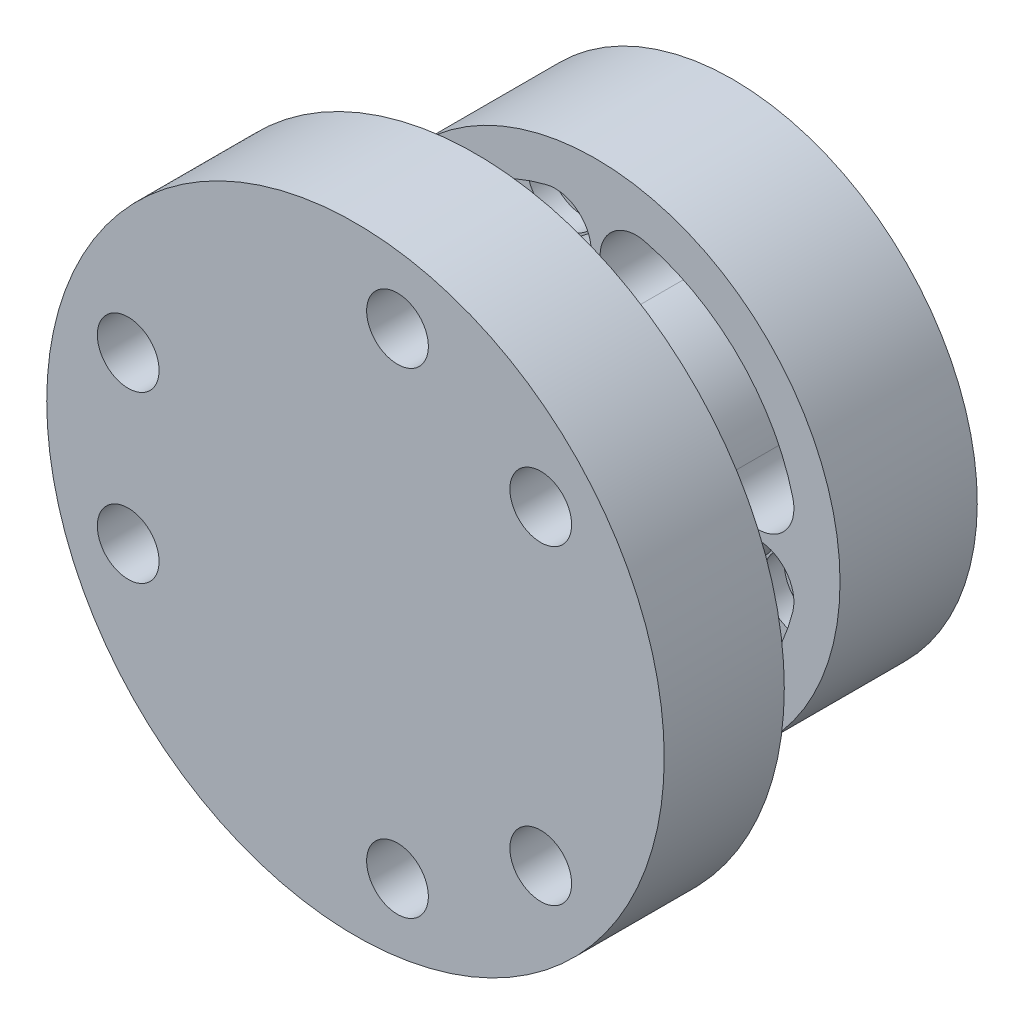
from build123d import *

# Parameters (mm, degrees)
SKETCH_1_R                   = 1.1
EXTRUDE_1_DEPTH              = 3
SKETCH_2_R                   = 2.1
CUT_EXTRUDE_1_DEPTH          = 1.2
SKETCH_3_R                   = 14.25
SKETCH_3_R_2                 = 11.85
EXTRUDE_2_DEPTH              = 1
SKETCH_4_R                   = 14.25
EXTRUDE_3_DEPTH              = 4
SKETCH_5_R                   = 3.25
CUT_EXTRUDE_2_DEPTH          = 2.5
SKETCH_6_R                   = 3.5
EXTRUDE_4_DEPTH              = 7
SKETCH_7_R                   = 18
SKETCH_7_R_2                 = 1.6
EXTRUDE_5_DEPTH              = 7
HOLE_WIZARD_M3_1_D           = 3.6
HOLE_WIZARD_M3_1_DEPTH       = 7
HOLE_WIZARD_M3_1_CSINK_D     = 6.3
HOLE_WIZARD_M3_1_CSINK_ANGLE = 90


with BuildPart() as part:
    # 스케치1 → 보스-돌출1 (new body)
    with BuildSketch(Plane.XY):
        with BuildLine():
            Line((-4.25, -5.562148865), (-4.25, -13.601470509))
            ThreePointArc((-4.25, -13.601470509), (0, 14.25), (4.25, -13.601470509))
            Line((4.25, -13.601470509), (4.25, -5.562148865))
            ThreePointArc((4.25, -5.562148865), (0, 7), (-4.25, -5.562148865))
        make_face()
        with Locations((6.894291117, 6.894291117)):
            Circle(SKETCH_1_R, mode=Mode.SUBTRACT)
        with Locations((6.894291117, -6.894291117)):
            Circle(SKETCH_1_R, mode=Mode.SUBTRACT)
        with Locations((-6.894291117, -6.894291117)):
            Circle(SKETCH_1_R, mode=Mode.SUBTRACT)
        with Locations((-6.894291117, 6.894291117)):
            Circle(SKETCH_1_R, mode=Mode.SUBTRACT)
    extrude(amount=EXTRUDE_1_DEPTH)

    # 스케치2 → 컷-돌출1 (cut)
    with BuildSketch(Plane.XY.offset(3)):
        with Locations((-6.894291117, 6.894291117)):
            Circle(SKETCH_2_R)
        with Locations((6.894291117, 6.894291117)):
            Circle(SKETCH_2_R)
        with Locations((6.894291117, -6.894291117)):
            Circle(SKETCH_2_R)
        with Locations((-6.894291117, -6.894291117)):
            Circle(SKETCH_2_R)
    extrude(amount=-CUT_EXTRUDE_1_DEPTH, mode=Mode.SUBTRACT)

    # 스케치3 → 보스-돌출2 (add)
    with BuildSketch(Plane.XY.offset(3)):
        Circle(SKETCH_3_R)
        Circle(SKETCH_3_R_2, mode=Mode.SUBTRACT)
    extrude(amount=EXTRUDE_2_DEPTH)

    # 스케치4 → 보스-돌출3 (add)
    with BuildSketch(Plane.XY.offset(4)):
        Circle(SKETCH_4_R)
        with BuildLine():
            ThreePointArc((11.498004356, 2.866774463), (8.379215357, 8.379215357), (2.866774463, 11.498004356))
            ThreePointArc((2.866774463, 11.498004356), (0.321117457, 9.968419312), (1.850702501, 7.422762306))
            ThreePointArc((1.850702501, 7.422762306), (5.409366876, 5.409366876), (7.422762306, 1.850702501))
            ThreePointArc((7.422762306, 1.850702501), (9.968419312, 0.321117457), (11.498004356, 2.866774463))
        make_face(mode=Mode.SUBTRACT)
        with BuildLine():
            ThreePointArc((2.866774463, -11.498004356), (8.379215357, -8.379215357), (11.498004356, -2.866774463))
            ThreePointArc((11.498004356, -2.866774463), (9.968419312, -0.321117457), (7.422762306, -1.850702501))
            ThreePointArc((7.422762306, -1.850702501), (5.409366876, -5.409366876), (1.850702501, -7.422762306))
            ThreePointArc((1.850702501, -7.422762306), (0.321117457, -9.968419312), (2.866774463, -11.498004356))
        make_face(mode=Mode.SUBTRACT)
        with BuildLine():
            ThreePointArc((-11.498004356, -2.866774463), (-8.379215357, -8.379215357), (-2.866774463, -11.498004356))
            ThreePointArc((-2.866774463, -11.498004356), (-0.321117457, -9.968419312), (-1.850702501, -7.422762306))
            ThreePointArc((-1.850702501, -7.422762306), (-5.409366876, -5.409366876), (-7.422762306, -1.850702501))
            ThreePointArc((-7.422762306, -1.850702501), (-9.968419312, -0.321117457), (-11.498004356, -2.866774463))
        make_face(mode=Mode.SUBTRACT)
        with BuildLine():
            ThreePointArc((-2.866774463, 11.498004356), (-8.379215357, 8.379215357), (-11.498004356, 2.866774463))
            ThreePointArc((-11.498004356, 2.866774463), (-9.968419312, 0.321117457), (-7.422762306, 1.850702501))
            ThreePointArc((-7.422762306, 1.850702501), (-5.409366876, 5.409366876), (-1.850702501, 7.422762306))
            ThreePointArc((-1.850702501, 7.422762306), (-0.321117457, 9.968419312), (-2.866774463, 11.498004356))
        make_face(mode=Mode.SUBTRACT)
        with BuildLine():
            ThreePointArc((3.40366883, 6.401370048), (0, 7.25), (-3.40366883, 6.401370048))
            ThreePointArc((-3.40366883, 6.401370048), (-4.023882875, 4.372741315), (-1.995254142, 3.75252727))
            ThreePointArc((-1.995254142, 3.75252727), (0, 4.25), (1.995254142, 3.75252727))
            ThreePointArc((1.995254142, 3.75252727), (4.023882875, 4.372741315), (3.40366883, 6.401370048))
        make_face(mode=Mode.SUBTRACT)
        with BuildLine():
            ThreePointArc((6.401370048, -3.40366883), (7.25, 0), (6.401370048, 3.40366883))
            ThreePointArc((6.401370048, 3.40366883), (4.372741315, 4.023882875), (3.75252727, 1.995254142))
            ThreePointArc((3.75252727, 1.995254142), (4.25, 0), (3.75252727, -1.995254142))
            ThreePointArc((3.75252727, -1.995254142), (4.372741315, -4.023882875), (6.401370048, -3.40366883))
        make_face(mode=Mode.SUBTRACT)
        with BuildLine():
            ThreePointArc((-3.40366883, -6.401370048), (0, -7.25), (3.40366883, -6.401370048))
            ThreePointArc((3.40366883, -6.401370048), (4.023882875, -4.372741315), (1.995254142, -3.75252727))
            ThreePointArc((1.995254142, -3.75252727), (0, -4.25), (-1.995254142, -3.75252727))
            ThreePointArc((-1.995254142, -3.75252727), (-4.023882875, -4.372741315), (-3.40366883, -6.401370048))
        make_face(mode=Mode.SUBTRACT)
        with BuildLine():
            ThreePointArc((-6.401370048, 3.40366883), (-7.25, 0), (-6.401370048, -3.40366883))
            ThreePointArc((-6.401370048, -3.40366883), (-4.372741315, -4.023882875), (-3.75252727, -1.995254142))
            ThreePointArc((-3.75252727, -1.995254142), (-4.25, 0), (-3.75252727, 1.995254142))
            ThreePointArc((-3.75252727, 1.995254142), (-4.372741315, 4.023882875), (-6.401370048, 3.40366883))
        make_face(mode=Mode.SUBTRACT)
    extrude(amount=EXTRUDE_3_DEPTH)

    # 스케치5 → 컷-돌출2 (cut)
    with BuildSketch(Plane(origin=(0, 0, 4), x_dir=(-1, 0, 0), z_dir=(0, 0, -1))):
        Circle(SKETCH_5_R)
    extrude(amount=-CUT_EXTRUDE_2_DEPTH, mode=Mode.SUBTRACT)

    # 스케치6 → 보스-돌출4 (add)
    with BuildSketch(Plane.XY.offset(8)):
        Circle(SKETCH_6_R)
    extrude(amount=EXTRUDE_4_DEPTH)

    # 스케치7 → 보스-돌출5 (add)
    with BuildSketch(Plane.XY.offset(15)):
        Circle(SKETCH_7_R)
        with Locations((-13.249665953, 4.822484021)):
            Circle(SKETCH_7_R_2, mode=Mode.SUBTRACT)
        with Locations((-13.249665953, -4.822484021)):
            Circle(SKETCH_7_R_2, mode=Mode.SUBTRACT)
        with Locations((10.801226648, 9.063305297)):
            Circle(SKETCH_7_R_2, mode=Mode.SUBTRACT)
        with Locations((2.448439305, 13.885789317)):
            Circle(SKETCH_7_R_2, mode=Mode.SUBTRACT)
        with Locations((2.448439305, -13.885789317)):
            Circle(SKETCH_7_R_2, mode=Mode.SUBTRACT)
        with Locations((10.801226648, -9.063305297)):
            Circle(SKETCH_7_R_2, mode=Mode.SUBTRACT)
    extrude(amount=EXTRUDE_5_DEPTH)

    # M3 접시 머리 나사용 카운터싱크1
    with Locations(Plane(origin=(2.448439305, 13.885789317, 15), x_dir=(-1, 0, 0), z_dir=(0, 0, -1))):
        with Locations((0, 0), (15.698105258, -9.063305296), (15.698105258, -18.708273338), (0, -27.771578634), (-8.352787343, -22.949094614), (-8.352787343, -4.82248402)):
            CounterSinkHole(HOLE_WIZARD_M3_1_D / 2, HOLE_WIZARD_M3_1_CSINK_D / 2, depth=HOLE_WIZARD_M3_1_DEPTH, counter_sink_angle=HOLE_WIZARD_M3_1_CSINK_ANGLE)


solid = part.part
